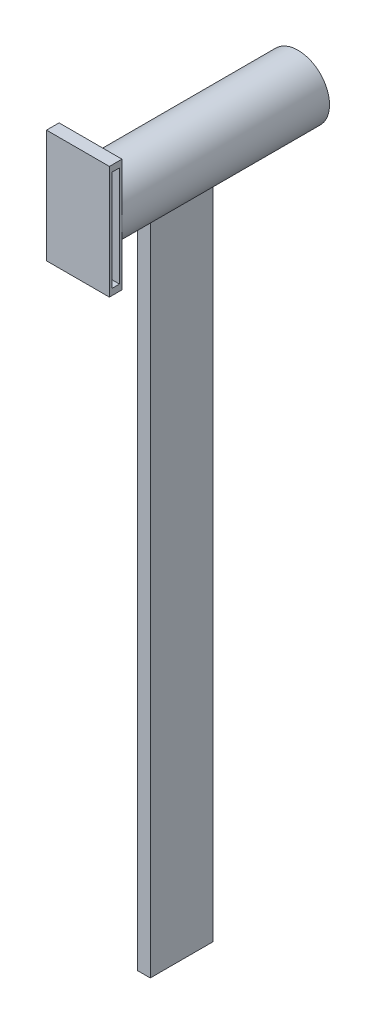
from build123d import *

# Parameters (mm, degrees)
SKETCH2_R               = 2.5
SKETCH3_R               = 2.5
SKETCH4_W               = 1
SKETCH4_H               = 5
BOSS_EXTRUDE1_DEPTH     = 55
SKETCH3_7_W             = 5
SKETCH3_7_H             = 9
BOSS_EXTRUDE4_DEPTH     = 1
CUT_EXTRUDE2_DEPTH      = 58.93315114
CUT_EXTRUDE2_DEPTH_BACK = 58.93315114
SKETCH8_W               = 0.6
SKETCH8_H               = 8


with BuildPart() as part:
    # Sketch2 → Loft1 section 0
    with BuildSketch(Plane.XY):
        Circle(SKETCH2_R)
    # Sketch3 → Loft1 section 1
    with BuildSketch(Plane.XY.offset(16.5)):
        Circle(SKETCH3_R)
    loft()

    # Sketch4 → Boss-Extrude1 (add)
    with BuildSketch(Plane(origin=(0, 0, 0), x_dir=(1, 0, 0), z_dir=(0, 1, 0))):
        with Locations((0, -9.75)):
            Rectangle(SKETCH4_W, SKETCH4_H)
    extrude(amount=-BOSS_EXTRUDE1_DEPTH)

    # Sketch3_7 → Boss-Extrude4 (add)
    with BuildSketch(Plane.XY.offset(16.5)):
        Rectangle(SKETCH3_7_W, SKETCH3_7_H)
    extrude(amount=BOSS_EXTRUDE4_DEPTH)

    # Sketch8 → Cut-Extrude2 (cut, two sides: drawn at the far end of the back side and taken through both)
    with BuildSketch(Plane(origin=(2.5, 0, 0), x_dir=(0, 0, -1), z_dir=(1, 0, 0)).offset(-CUT_EXTRUDE2_DEPTH_BACK)):
        with Locations((-17, 0)):
            Rectangle(SKETCH8_W, SKETCH8_H)
    extrude(amount=CUT_EXTRUDE2_DEPTH + CUT_EXTRUDE2_DEPTH_BACK, mode=Mode.SUBTRACT)


solid = part.part
